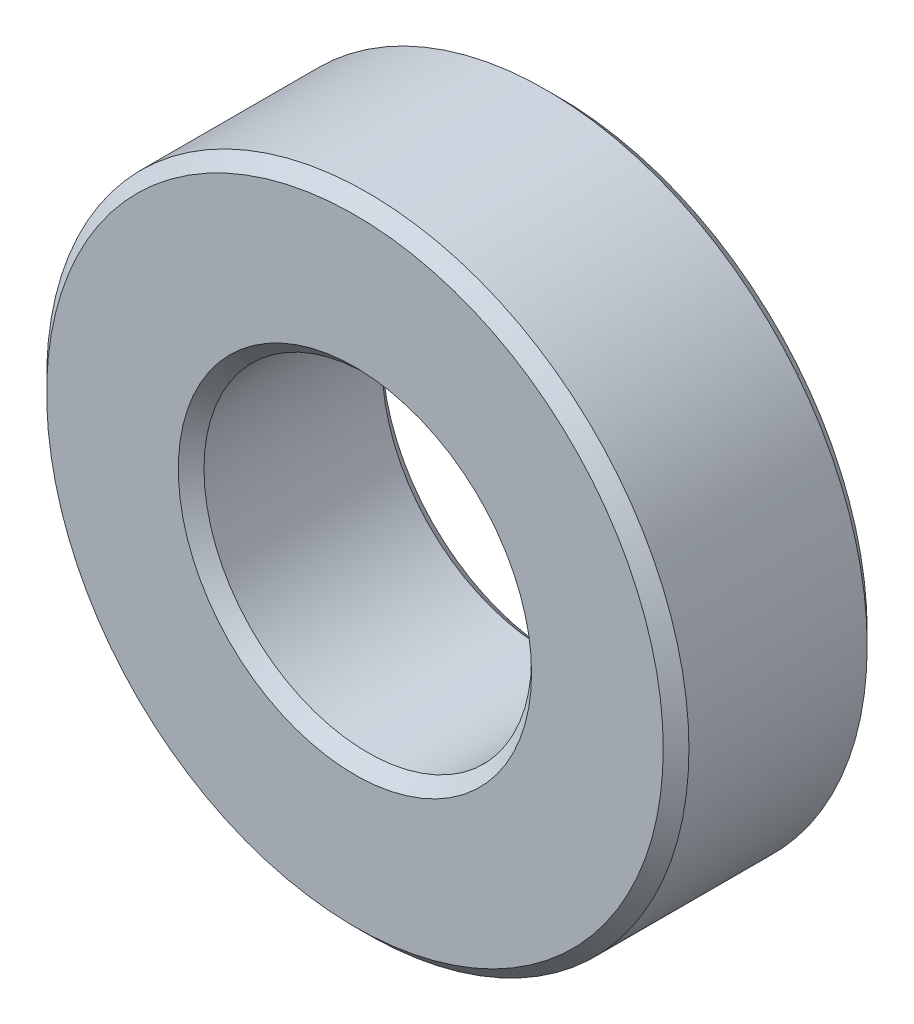
from build123d import *

# Parameters (mm, degrees)
SKETCH1_R           = 5
SKETCH1_R_2         = 2.55
BOSS_EXTRUDE1_DEPTH = 3.175
CHAMFER1_SIZE       = 0.2


with BuildPart() as part:
    # Sketch1 → Boss-Extrude1 (new body)
    with BuildSketch(Plane.XY):
        Circle(SKETCH1_R)
        Circle(SKETCH1_R_2, mode=Mode.SUBTRACT)
    extrude(amount=BOSS_EXTRUDE1_DEPTH)

    # Chamfer1
    chamfer1_edges = [part.edges().sort_by_distance(p)[0] for p in [
        (-5, 0, 0),
        (-5, 0, 3.175),
        (-2.55, 0, 0),
        (-2.55, 0, 3.175),
    ]]
    chamfer(chamfer1_edges, length=CHAMFER1_SIZE)


solid = part.part
